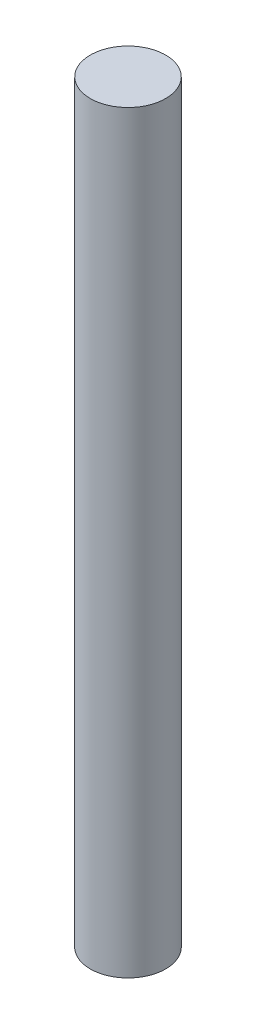
from build123d import *

# Parameters (mm, degrees)
SKETCH1_R           = 1.27
BOSS_EXTRUDE1_DEPTH = 25.4


with BuildPart() as part:
    # Sketch1 → Boss-Extrude1 (new body)
    with BuildSketch(Plane(origin=(0, 0, 0), x_dir=(1, 0, 0), z_dir=(0, 1, 0))):
        with Locations(Location((0, 0, 0), (0, 0, 270))):  # turned: the seam where the file's is
            Circle(SKETCH1_R)
    extrude(amount=BOSS_EXTRUDE1_DEPTH)


solid = part.part
